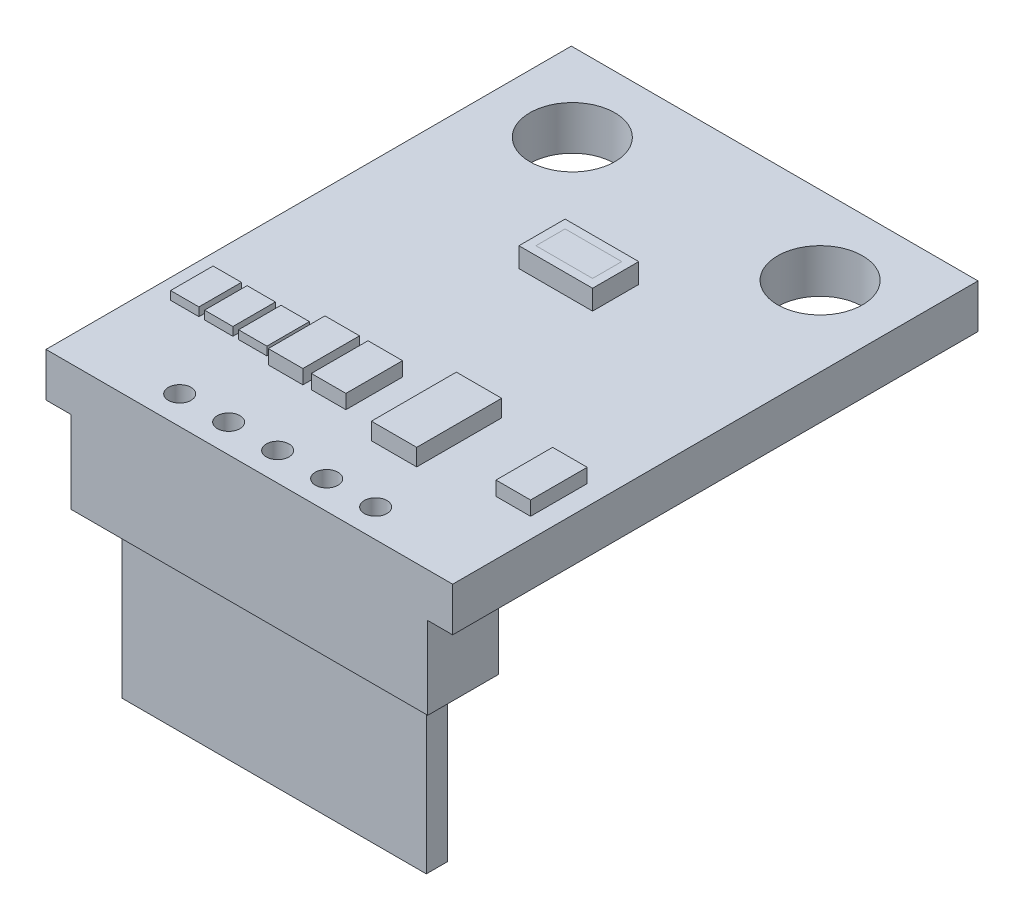
from build123d import *

# Parameters (mm, degrees)
SKETCH1_W           = 14.36
SKETCH1_H           = 18.55
BOSS_EXTRUDE1_DEPTH = 1.55
SKETCH2_R           = 1.5
SKETCH2_R_2         = 0.4
CUT_EXTRUDE1_DEPTH  = 2.55
SKETCH5_W           = 2.6
SKETCH5_H           = 1.63
SENSOR_DEPTH        = 0.7
SKETCH6_W           = 1
SKETCH6_H           = 1.5
CAPACITORS1_DEPTH   = 0.3
SKETCH7_W           = 1.22
SKETCH7_H           = 2
CAPACITORS2_DEPTH   = 0.5
SKETCH8_W           = 1.6
SKETCH8_H           = 3
MISC_CHIP1_DEPTH    = 0.6
SKETCH10_W          = 12.6
SKETCH10_H          = 2.5
BOSS_EXTRUDE2_DEPTH = 2.9
SKETCH12_W          = 10.75
SKETCH12_H          = 0.75
BOSS_EXTRUDE3_DEPTH = 5.75


with BuildPart() as part:
    # Sketch1 → Boss-Extrude1 (new body)
    with BuildSketch(Plane(origin=(0, 0, 0), x_dir=(1, 0, 0), z_dir=(0, 1, 0))):
        Rectangle(SKETCH1_W, SKETCH1_H)
    extrude(amount=BOSS_EXTRUDE1_DEPTH)

    # Sketch2 → Cut-Extrude1 (cut, through all)
    with BuildSketch(Plane(origin=(0, 1.55, 0), x_dir=(1, 0, 0), z_dir=(0, 1, 0))):
        with Locations((-4.375, 6.505)):
            Circle(SKETCH2_R)
        with Locations((4.375, 6.505)):
            Circle(SKETCH2_R)
        with Locations((-1.73, -8.275)):
            Circle(SKETCH2_R_2)
        with Locations((1.73, -8.275)):
            Circle(SKETCH2_R_2)
        with Locations((3.46, -8.275)):
            Circle(SKETCH2_R_2)
        with Locations((-3.46, -8.275)):
            Circle(SKETCH2_R_2)
        with Locations((0, -8.275)):
            Circle(SKETCH2_R_2)
    extrude(amount=-CUT_EXTRUDE1_DEPTH, mode=Mode.SUBTRACT)

    # Sketch5 → Sensor (add)
    with BuildSketch(Plane(origin=(0, 1.55, 0), x_dir=(1, 0, 0), z_dir=(0, 1, 0))):
        with Locations((0, 2.36)):
            Rectangle(SKETCH5_W, SKETCH5_H)
    extrude(amount=SENSOR_DEPTH)

    # Sketch6 → Capacitors1 (add)
    with BuildSketch(Plane(origin=(0, 1.55, 0), x_dir=(1, 0, 0), z_dir=(0, 1, 0))):
        with Locations((-5.98, -4.825)):
            Rectangle(SKETCH6_W, SKETCH6_H)
        with Locations((-4.78, -4.825)):
            Rectangle(SKETCH6_W, SKETCH6_H)
        with Locations((-3.58, -4.825)):
            Rectangle(SKETCH6_W, SKETCH6_H)
    extrude(amount=CAPACITORS1_DEPTH)

    # Sketch7 → Capacitors2 (add)
    with BuildSketch(Plane(origin=(0, 1.55, 0), x_dir=(1, 0, 0), z_dir=(0, 1, 0))):
        with Locations((-2.17, -4.825)):
            Rectangle(SKETCH7_W, SKETCH7_H)
        with Locations((-0.65, -4.825)):
            Rectangle(SKETCH7_W, SKETCH7_H)
        with Locations((5.87, -4.825)):
            Rectangle(SKETCH7_W, SKETCH7_H)
    extrude(amount=CAPACITORS2_DEPTH)

    # Sketch8 → misc.chip1 (add)
    with BuildSketch(Plane(origin=(0, 1.55, 0), x_dir=(1, 0, 0), z_dir=(0, 1, 0))):
        with Locations((2.16, -4.825)):
            Rectangle(SKETCH8_W, SKETCH8_H)
    extrude(amount=MISC_CHIP1_DEPTH)

    # Sketch10 → Boss-Extrude2 (add)
    with BuildSketch(Plane.XZ):
        with Locations((0, 8.025)):
            Rectangle(SKETCH10_W, SKETCH10_H)
    extrude(amount=BOSS_EXTRUDE2_DEPTH)

    # Sketch12 → Boss-Extrude3 (add)
    with BuildSketch(Plane.XZ.offset(2.9)):
        with Locations((0, 8.025)):
            Rectangle(SKETCH12_W, SKETCH12_H)
    extrude(amount=BOSS_EXTRUDE3_DEPTH)


solid = part.part
